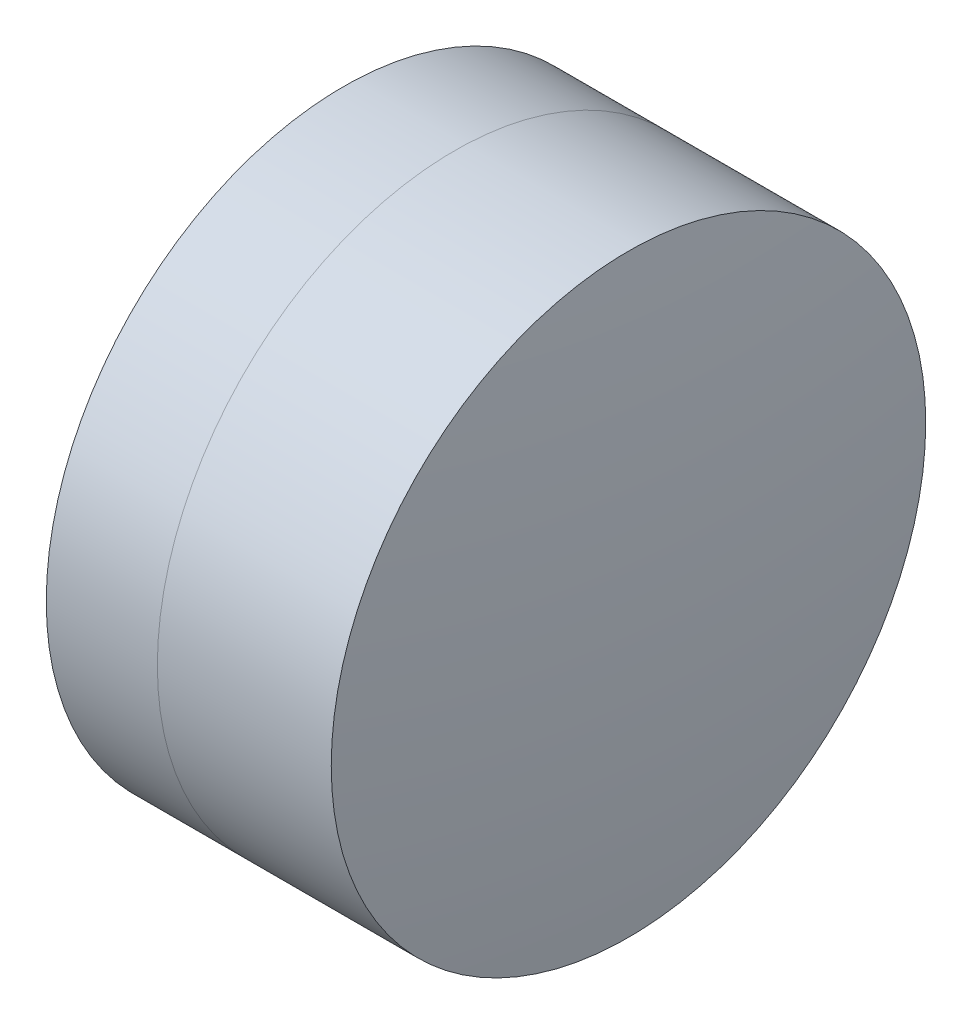
from build123d import *


with BuildPart() as part:
    # 草图1 one side → 旋转1 (revolve)
    with BuildSketch(Plane(origin=(0, 0, 0), x_dir=(1, 0, 0), z_dir=(0, 1, 0)), mode=Mode.PRIVATE) as revolve_1_sk:
        with BuildLine():
            ThreePointArc((-2.194082493, 5), (-3.083481295, 2.569985762), (-3.385429321, 0))
            Line((-3.385429321, 0), (1.414570679, 0))
            ThreePointArc((1.414570679, 0), (0.967149282, 2.647050803), (-0.325403981, 5))
            Line((-0.325403981, 5), (-2.194082493, 5))
        make_face()
    revolve(revolve_1_sk.sketch.rotate(Axis((-9.702612178, 0, 0), (1, 0, 0)), 180), axis=Axis((-9.702612178, 0, 0), (1, 0, 0)))  # turned: the seam where the file's is


with BuildPart() as body_2:
    # 草图2 one side → 旋转3 (revolve)
    with BuildSketch(Plane(origin=(0, 0, 0), x_dir=(1, 0, 0), z_dir=(0, 1, 0)), mode=Mode.PRIVATE) as revolve_3_sk:
        with BuildLine():
            Line((2.599331091, 5), (-0.325403981, 5))
            ThreePointArc((-0.325403981, 5), (0.967149282, 2.647050803), (1.414570679, 0))
            Line((1.414570679, 0), (2.914570679, 0))
            ThreePointArc((2.914570679, 0), (2.835682619, 2.504963872), (2.599331091, 5))
        make_face()
    revolve(revolve_3_sk.sketch.rotate(Axis((-0.551919993, 0, 0), (1, 0, 0)), 180), axis=Axis((-0.551919993, 0, 0), (1, 0, 0)))  # turned: the seam where the file's is


solid = Compound([part.part, body_2.part])
